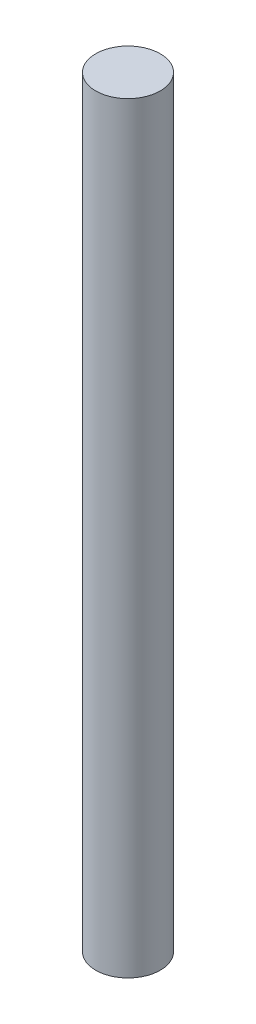
from build123d import *

# Parameters (mm, degrees)
SKETCH1_R           = 6.35
BOSS_EXTRUDE1_DEPTH = 150


with BuildPart() as part:
    # Sketch1 → Boss-Extrude1 (new body)
    with BuildSketch(Plane(origin=(0, 0, 0), x_dir=(1, 0, 0), z_dir=(0, 1, 0))):
        Circle(SKETCH1_R)
    extrude(amount=BOSS_EXTRUDE1_DEPTH)


solid = part.part
